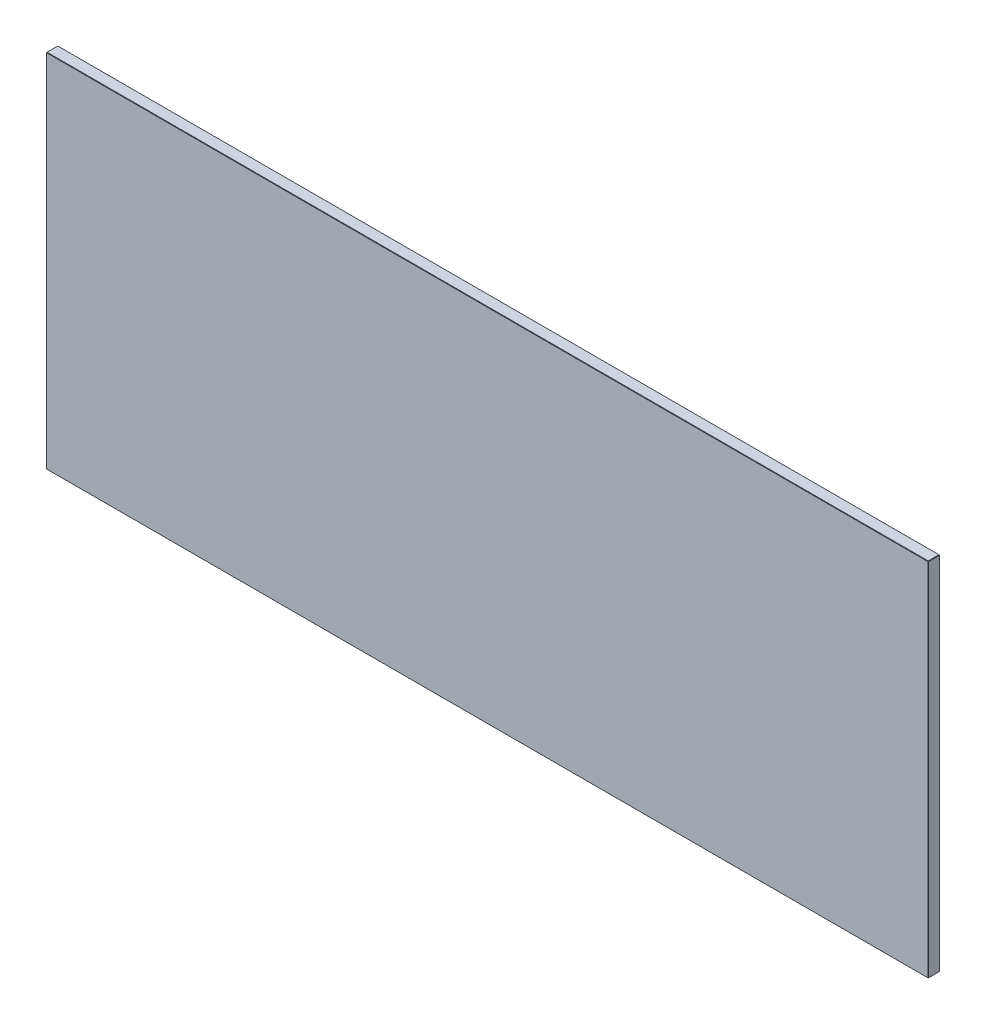
from build123d import *

# Parameters (mm, degrees)
SKETCH1_W           = 732.5
SKETCH1_H           = 300
BOSS_EXTRUDE1_DEPTH = 9.5
CHAMFER1_SIZE       = 0.3


with BuildPart() as part:
    # Sketch1 → Boss-Extrude1 (new body)
    with BuildSketch(Plane(origin=(15.083033638, 7.228664087, 0), x_dir=(1, 0, 0), z_dir=(0, 0, 1))):
        with Locations((-341.25, -140)):
            Rectangle(SKETCH1_W, SKETCH1_H)
    extrude(amount=BOSS_EXTRUDE1_DEPTH)

    # Chamfer1
    chamfer1_edges = [part.edges().sort_by_distance(p)[0] for p in [
        (40.083033638, -282.771335913, 4.75),
        (-326.166966362, -282.771335913, 0),
        (-326.166966362, -282.771335913, 9.5),
        (-692.416966362, -282.771335913, 4.75),
        (-692.416966362, -132.771335913, 0),
        (-692.416966362, -132.771335913, 9.5),
        (40.083033638, -132.771335913, 9.5),
        (40.083033638, -132.771335913, 0),
        (-326.166966362, 17.228664087, 0),
        (40.083033638, 17.228664087, 4.75),
        (-692.416966362, 17.228664087, 4.75),
        (-326.166966362, 17.228664087, 9.5),
    ]]
    chamfer(chamfer1_edges, length=CHAMFER1_SIZE)


solid = part.part
